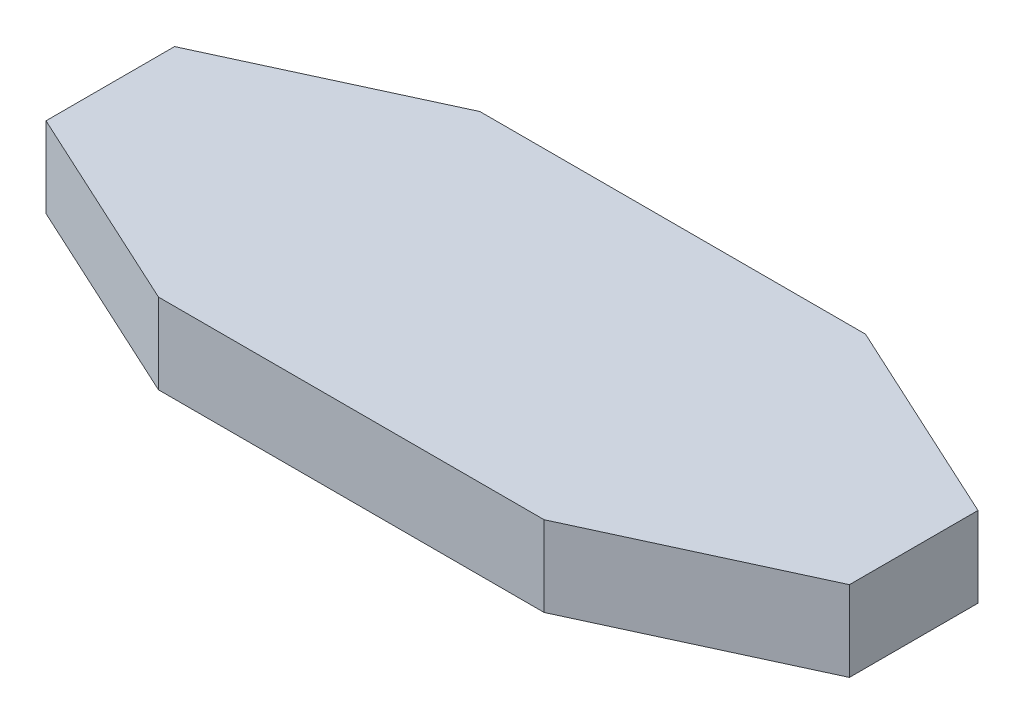
from build123d import *

# Parameters (mm, degrees)
BOSS_EXTRUDE1_DEPTH = 25


with BuildPart() as part:
    # Sketch1 → Boss-Extrude1 (new body)
    with BuildSketch(Plane(origin=(0, 0, 0), x_dir=(1, 0, 0), z_dir=(0, 1, 0))):
        Polygon((-60, 50), (60, 50), (125, 20), (125, -20), (60, -50), (-60, -50), (-125, -20), (-125, 20), align=None)
    extrude(amount=BOSS_EXTRUDE1_DEPTH)


solid = part.part
